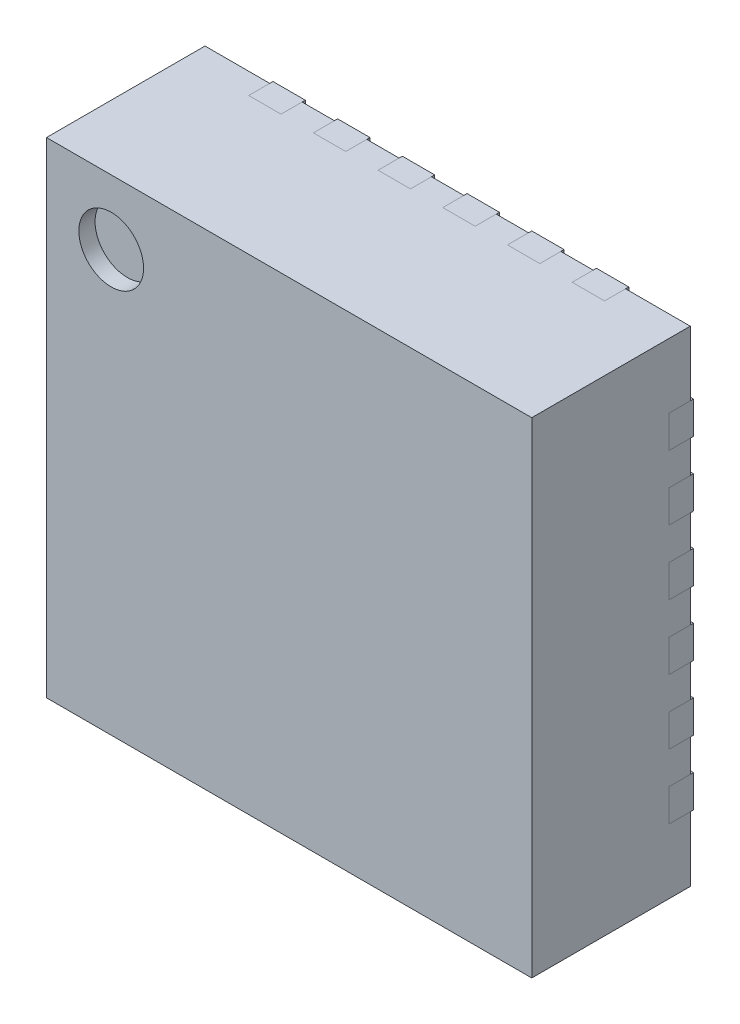
from build123d import *

# Parameters (mm, degrees)
ESQUISSE1_W                = 3
ESQUISSE1_H                = 3
BOSS_EXTRU_1_DEPTH         = 0.98
ENL_V_MAT_EXTRU_3_DEPTH    = 0.13
BOSS_EXTRU_3_DEPTH         = 0.13
BOSS_EXTRU_3_DEPTH_BACK    = 0.02
BOSS_EXTRU_3_2_DEPTH       = 0.13
BOSS_EXTRU_3_2_DEPTH_BACK  = 0.02
BOSS_EXTRU_3_3_DEPTH       = 0.13
BOSS_EXTRU_3_3_DEPTH_BACK  = 0.02
BOSS_EXTRU_3_4_DEPTH       = 0.13
BOSS_EXTRU_3_4_DEPTH_BACK  = 0.02
BOSS_EXTRU_3_5_DEPTH       = 0.13
BOSS_EXTRU_3_5_DEPTH_BACK  = 0.02
BOSS_EXTRU_3_6_DEPTH       = 0.13
BOSS_EXTRU_3_6_DEPTH_BACK  = 0.02
BOSS_EXTRU_3_7_DEPTH       = 0.13
BOSS_EXTRU_3_7_DEPTH_BACK  = 0.02
BOSS_EXTRU_3_8_DEPTH       = 0.13
BOSS_EXTRU_3_8_DEPTH_BACK  = 0.02
BOSS_EXTRU_3_9_DEPTH       = 0.13
BOSS_EXTRU_3_9_DEPTH_BACK  = 0.02
BOSS_EXTRU_3_10_DEPTH      = 0.13
BOSS_EXTRU_3_10_DEPTH_BACK = 0.02
BOSS_EXTRU_3_11_DEPTH      = 0.13
BOSS_EXTRU_3_11_DEPTH_BACK = 0.02
BOSS_EXTRU_3_12_DEPTH      = 0.13
BOSS_EXTRU_3_12_DEPTH_BACK = 0.02
BOSS_EXTRU_3_13_DEPTH      = 0.13
BOSS_EXTRU_3_13_DEPTH_BACK = 0.02
BOSS_EXTRU_3_14_DEPTH      = 0.13
BOSS_EXTRU_3_14_DEPTH_BACK = 0.02
BOSS_EXTRU_3_15_DEPTH      = 0.13
BOSS_EXTRU_3_15_DEPTH_BACK = 0.02
BOSS_EXTRU_3_16_DEPTH      = 0.13
BOSS_EXTRU_3_16_DEPTH_BACK = 0.02
BOSS_EXTRU_3_17_DEPTH      = 0.13
BOSS_EXTRU_3_17_DEPTH_BACK = 0.02
BOSS_EXTRU_3_18_DEPTH      = 0.13
BOSS_EXTRU_3_18_DEPTH_BACK = 0.02
BOSS_EXTRU_3_19_DEPTH      = 0.13
BOSS_EXTRU_3_19_DEPTH_BACK = 0.02
BOSS_EXTRU_3_20_DEPTH      = 0.13
BOSS_EXTRU_3_20_DEPTH_BACK = 0.02
BOSS_EXTRU_3_21_DEPTH      = 0.13
BOSS_EXTRU_3_21_DEPTH_BACK = 0.02
BOSS_EXTRU_3_22_DEPTH      = 0.13
BOSS_EXTRU_3_22_DEPTH_BACK = 0.02
BOSS_EXTRU_3_23_DEPTH      = 0.13
BOSS_EXTRU_3_23_DEPTH_BACK = 0.02
BOSS_EXTRU_3_24_DEPTH      = 0.13
BOSS_EXTRU_3_24_DEPTH_BACK = 0.02
BOSS_EXTRU_3_25_DEPTH      = 0.13
BOSS_EXTRU_3_25_DEPTH_BACK = 0.02
ESQUISSE5_R                = 0.2
ENL_V_MAT_EXTRU_4_DEPTH    = 0.1


with BuildPart() as part:
    # Esquisse1 → Boss.-Extru.1 (new body)
    with BuildSketch(Plane.XY):
        Rectangle(ESQUISSE1_W, ESQUISSE1_H)
    extrude(amount=BOSS_EXTRU_1_DEPTH)

    # Esquisse3 → Enlèv. mat.-Extru.3 (cut)
    with BuildSketch(Plane.XY):
        with BuildLine():
            Line((-1.275, -0.5), (-1.5, -0.5))
            Line((-1.5, -0.5), (-1.5, -0.7))
            Line((-1.5, -0.7), (-1.275, -0.7))
            ThreePointArc((-1.275, -0.7), (-1.221966991, -0.678033009), (-1.2, -0.625))
            Line((-1.2, -0.625), (-1.2, -0.575))
            ThreePointArc((-1.2, -0.575), (-1.221966991, -0.521966991), (-1.275, -0.5))
        make_face()
        with BuildLine():
            Line((0.85, 0.62), (0.85, -0.62))
            ThreePointArc((0.85, -0.62), (0.806066017, -0.726066017), (0.7, -0.77))
            Line((0.7, -0.77), (-0.7, -0.77))
            ThreePointArc((-0.7, -0.77), (-0.806066017, -0.726066017), (-0.85, -0.62))
            Line((-0.85, -0.62), (-0.85, 0.52))
            Line((-0.85, 0.52), (-0.6, 0.77))
            Line((-0.6, 0.77), (0.7, 0.77))
            ThreePointArc((0.7, 0.77), (0.806066017, 0.726066017), (0.85, 0.62))
        make_face()
        with BuildLine():
            Line((-1.5, 1.1), (-1.28, 1.1))
            ThreePointArc((-1.28, 1.1), (-1.220323996, 1.053117336), (-1.2, 0.98))
            ThreePointArc((-1.2, 0.98), (-1.223431458, 0.923431458), (-1.28, 0.9))
            Line((-1.28, 0.9), (-1.5, 0.9))
            Line((-1.5, 0.9), (-1.5, 1.1))
        make_face()
        with BuildLine():
            Line((-1.5, -0.1), (-1.5, -0.3))
            Line((-1.5, -0.3), (-1.275, -0.3))
            ThreePointArc((-1.275, -0.3), (-1.221966991, -0.278033009), (-1.2, -0.225))
            Line((-1.2, -0.225), (-1.2, -0.175))
            ThreePointArc((-1.2, -0.175), (-1.221966991, -0.121966991), (-1.275, -0.1))
            Line((-1.275, -0.1), (-1.5, -0.1))
        make_face()
        with BuildLine():
            Line((-1.5, 0.3), (-1.5, 0.1))
            Line((-1.5, 0.1), (-1.275, 0.1))
            ThreePointArc((-1.275, 0.1), (-1.221966991, 0.121966991), (-1.2, 0.175))
            Line((-1.2, 0.175), (-1.2, 0.225))
            ThreePointArc((-1.2, 0.225), (-1.221966991, 0.278033009), (-1.275, 0.3))
            Line((-1.275, 0.3), (-1.5, 0.3))
        make_face()
        with BuildLine():
            Line((-1.5, 0.7), (-1.5, 0.5))
            Line((-1.5, 0.5), (-1.275, 0.5))
            ThreePointArc((-1.275, 0.5), (-1.221966991, 0.521966991), (-1.2, 0.575))
            Line((-1.2, 0.575), (-1.2, 0.625))
            ThreePointArc((-1.2, 0.625), (-1.221966991, 0.678033009), (-1.275, 0.7))
            Line((-1.275, 0.7), (-1.5, 0.7))
        make_face()
        with BuildLine():
            Line((-1.5, -0.9), (-1.5, -1.1))
            Line((-1.5, -1.1), (-1.28, -1.1))
            ThreePointArc((-1.28, -1.1), (-1.220323996, -1.053117336), (-1.2, -0.98))
            ThreePointArc((-1.2, -0.98), (-1.223431458, -0.923431458), (-1.28, -0.9))
            Line((-1.28, -0.9), (-1.5, -0.9))
        make_face()
        with BuildLine():
            Line((1.1, 1.5), (1.1, 1.28))
            ThreePointArc((1.1, 1.28), (1.053117336, 1.220323996), (0.98, 1.2))
            ThreePointArc((0.98, 1.2), (0.923431458, 1.223431458), (0.9, 1.28))
            Line((0.9, 1.28), (0.9, 1.5))
            Line((0.9, 1.5), (1.1, 1.5))
        make_face()
        with BuildLine():
            Line((0.7, 1.5), (0.5, 1.5))
            Line((0.5, 1.5), (0.5, 1.275))
            ThreePointArc((0.5, 1.275), (0.521966991, 1.221966991), (0.575, 1.2))
            Line((0.575, 1.2), (0.625, 1.2))
            ThreePointArc((0.625, 1.2), (0.678033009, 1.221966991), (0.7, 1.275))
            Line((0.7, 1.275), (0.7, 1.5))
        make_face()
        with BuildLine():
            Line((0.3, 1.5), (0.1, 1.5))
            Line((0.1, 1.5), (0.1, 1.275))
            ThreePointArc((0.1, 1.275), (0.121966991, 1.221966991), (0.175, 1.2))
            Line((0.175, 1.2), (0.225, 1.2))
            ThreePointArc((0.225, 1.2), (0.278033009, 1.221966991), (0.3, 1.275))
            Line((0.3, 1.275), (0.3, 1.5))
        make_face()
        with BuildLine():
            Line((-0.1, 1.5), (-0.3, 1.5))
            Line((-0.3, 1.5), (-0.3, 1.275))
            ThreePointArc((-0.3, 1.275), (-0.278033009, 1.221966991), (-0.225, 1.2))
            Line((-0.225, 1.2), (-0.175, 1.2))
            ThreePointArc((-0.175, 1.2), (-0.121966991, 1.221966991), (-0.1, 1.275))
            Line((-0.1, 1.275), (-0.1, 1.5))
        make_face()
        with BuildLine():
            Line((1.5, -1.1), (1.28, -1.1))
            ThreePointArc((1.28, -1.1), (1.220323996, -1.053117336), (1.2, -0.98))
            ThreePointArc((1.2, -0.98), (1.223431458, -0.923431458), (1.28, -0.9))
            Line((1.28, -0.9), (1.5, -0.9))
            Line((1.5, -0.9), (1.5, -1.1))
        make_face()
        with BuildLine():
            Line((1.5, -0.7), (1.5, -0.5))
            Line((1.5, -0.5), (1.275, -0.5))
            ThreePointArc((1.275, -0.5), (1.221966991, -0.521966991), (1.2, -0.575))
            Line((1.2, -0.575), (1.2, -0.625))
            ThreePointArc((1.2, -0.625), (1.221966991, -0.678033009), (1.275, -0.7))
            Line((1.275, -0.7), (1.5, -0.7))
        make_face()
        with BuildLine():
            Line((1.5, -0.3), (1.5, -0.1))
            Line((1.5, -0.1), (1.275, -0.1))
            ThreePointArc((1.275, -0.1), (1.221966991, -0.121966991), (1.2, -0.175))
            Line((1.2, -0.175), (1.2, -0.225))
            ThreePointArc((1.2, -0.225), (1.221966991, -0.278033009), (1.275, -0.3))
            Line((1.275, -0.3), (1.5, -0.3))
        make_face()
        with BuildLine():
            Line((1.5, 0.1), (1.5, 0.3))
            Line((1.5, 0.3), (1.275, 0.3))
            ThreePointArc((1.275, 0.3), (1.221966991, 0.278033009), (1.2, 0.225))
            Line((1.2, 0.225), (1.2, 0.175))
            ThreePointArc((1.2, 0.175), (1.221966991, 0.121966991), (1.275, 0.1))
            Line((1.275, 0.1), (1.5, 0.1))
        make_face()
        with BuildLine():
            Line((-1.1, -1.5), (-1.1, -1.28))
            ThreePointArc((-1.1, -1.28), (-1.053117336, -1.220323996), (-0.98, -1.2))
            ThreePointArc((-0.98, -1.2), (-0.923431458, -1.223431458), (-0.9, -1.28))
            Line((-0.9, -1.28), (-0.9, -1.5))
            Line((-0.9, -1.5), (-1.1, -1.5))
        make_face()
        with BuildLine():
            Line((-0.7, -1.5), (-0.5, -1.5))
            Line((-0.5, -1.5), (-0.5, -1.275))
            ThreePointArc((-0.5, -1.275), (-0.521966991, -1.221966991), (-0.575, -1.2))
            Line((-0.575, -1.2), (-0.625, -1.2))
            ThreePointArc((-0.625, -1.2), (-0.678033009, -1.221966991), (-0.7, -1.275))
            Line((-0.7, -1.275), (-0.7, -1.5))
        make_face()
        with BuildLine():
            Line((-0.3, -1.5), (-0.1, -1.5))
            Line((-0.1, -1.5), (-0.1, -1.275))
            ThreePointArc((-0.1, -1.275), (-0.121966991, -1.221966991), (-0.175, -1.2))
            Line((-0.175, -1.2), (-0.225, -1.2))
            ThreePointArc((-0.225, -1.2), (-0.278033009, -1.221966991), (-0.3, -1.275))
            Line((-0.3, -1.275), (-0.3, -1.5))
        make_face()
        with BuildLine():
            Line((0.1, -1.5), (0.3, -1.5))
            Line((0.3, -1.5), (0.3, -1.275))
            ThreePointArc((0.3, -1.275), (0.278033009, -1.221966991), (0.225, -1.2))
            Line((0.225, -1.2), (0.175, -1.2))
            ThreePointArc((0.175, -1.2), (0.121966991, -1.221966991), (0.1, -1.275))
            Line((0.1, -1.275), (0.1, -1.5))
        make_face()
        with BuildLine():
            Line((-0.5, 1.5), (-0.7, 1.5))
            Line((-0.7, 1.5), (-0.7, 1.275))
            ThreePointArc((-0.7, 1.275), (-0.678033009, 1.221966991), (-0.625, 1.2))
            Line((-0.625, 1.2), (-0.575, 1.2))
            ThreePointArc((-0.575, 1.2), (-0.521966991, 1.221966991), (-0.5, 1.275))
            Line((-0.5, 1.275), (-0.5, 1.5))
        make_face()
        with BuildLine():
            Line((-0.9, 1.5), (-1.1, 1.5))
            Line((-1.1, 1.5), (-1.1, 1.28))
            ThreePointArc((-1.1, 1.28), (-1.053117336, 1.220323996), (-0.98, 1.2))
            ThreePointArc((-0.98, 1.2), (-0.923431458, 1.223431458), (-0.9, 1.28))
            Line((-0.9, 1.28), (-0.9, 1.5))
        make_face()
        with BuildLine():
            Line((1.5, 0.5), (1.5, 0.7))
            Line((1.5, 0.7), (1.275, 0.7))
            ThreePointArc((1.275, 0.7), (1.221966991, 0.678033009), (1.2, 0.625))
            Line((1.2, 0.625), (1.2, 0.575))
            ThreePointArc((1.2, 0.575), (1.221966991, 0.521966991), (1.275, 0.5))
            Line((1.275, 0.5), (1.5, 0.5))
        make_face()
        with BuildLine():
            Line((1.5, 0.9), (1.5, 1.1))
            Line((1.5, 1.1), (1.28, 1.1))
            ThreePointArc((1.28, 1.1), (1.220323996, 1.053117336), (1.2, 0.98))
            ThreePointArc((1.2, 0.98), (1.223431458, 0.923431458), (1.28, 0.9))
            Line((1.28, 0.9), (1.5, 0.9))
        make_face()
        with BuildLine():
            Line((0.5, -1.5), (0.7, -1.5))
            Line((0.7, -1.5), (0.7, -1.275))
            ThreePointArc((0.7, -1.275), (0.678033009, -1.221966991), (0.625, -1.2))
            Line((0.625, -1.2), (0.575, -1.2))
            ThreePointArc((0.575, -1.2), (0.521966991, -1.221966991), (0.5, -1.275))
            Line((0.5, -1.275), (0.5, -1.5))
        make_face()
        with BuildLine():
            Line((0.9, -1.5), (1.1, -1.5))
            Line((1.1, -1.5), (1.1, -1.28))
            ThreePointArc((1.1, -1.28), (1.053117336, -1.220323996), (0.98, -1.2))
            ThreePointArc((0.98, -1.2), (0.923431458, -1.223431458), (0.9, -1.28))
            Line((0.9, -1.28), (0.9, -1.5))
        make_face()
    extrude(amount=ENL_V_MAT_EXTRU_3_DEPTH, mode=Mode.SUBTRACT)

    # Esquisse5 → Enlèv. mat.-Extru.4 (cut)
    with BuildSketch(Plane.XY.offset(0.98)):
        with Locations((-1.1, 1.1)):
            Circle(ESQUISSE5_R)
    extrude(amount=-ENL_V_MAT_EXTRU_4_DEPTH, mode=Mode.SUBTRACT)


with BuildPart() as body_2:
    # Esquisse4 → Boss.-Extru.3 (new body, two sides)
    with BuildSketch(Plane.XY) as boss_extru_3_sk:
        with BuildLine():
            Line((-1.275, -0.5), (-1.5, -0.5))
            Line((-1.5, -0.5), (-1.5, -0.7))
            Line((-1.5, -0.7), (-1.275, -0.7))
            ThreePointArc((-1.275, -0.7), (-1.221966991, -0.678033009), (-1.2, -0.625))
            Line((-1.2, -0.625), (-1.2, -0.575))
            ThreePointArc((-1.2, -0.575), (-1.221966991, -0.521966991), (-1.275, -0.5))
        make_face()
    extrude(amount=BOSS_EXTRU_3_DEPTH)
    extrude(boss_extru_3_sk.sketch, amount=-BOSS_EXTRU_3_DEPTH_BACK)


with BuildPart() as body_3:
    # Esquisse4 → Boss.-Extru.3 2 (new body, two sides)
    with BuildSketch(Plane.XY) as boss_extru_3_2_sk:
        with BuildLine():
            Line((0.85, 0.62), (0.85, -0.62))
            ThreePointArc((0.85, -0.62), (0.806066017, -0.726066017), (0.7, -0.77))
            Line((0.7, -0.77), (-0.7, -0.77))
            ThreePointArc((-0.7, -0.77), (-0.806066017, -0.726066017), (-0.85, -0.62))
            Line((-0.85, -0.62), (-0.85, 0.52))
            Line((-0.85, 0.52), (-0.6, 0.77))
            Line((-0.6, 0.77), (0.7, 0.77))
            ThreePointArc((0.7, 0.77), (0.806066017, 0.726066017), (0.85, 0.62))
        make_face()
    extrude(amount=BOSS_EXTRU_3_2_DEPTH)
    extrude(boss_extru_3_2_sk.sketch, amount=-BOSS_EXTRU_3_2_DEPTH_BACK)


with BuildPart() as body_4:
    # Esquisse4 → Boss.-Extru.3 3 (new body, two sides)
    with BuildSketch(Plane.XY) as boss_extru_3_3_sk:
        with BuildLine():
            Line((-1.5, 1.1), (-1.28, 1.1))
            ThreePointArc((-1.28, 1.1), (-1.220323996, 1.053117336), (-1.2, 0.98))
            ThreePointArc((-1.2, 0.98), (-1.223431458, 0.923431458), (-1.28, 0.9))
            Line((-1.28, 0.9), (-1.5, 0.9))
            Line((-1.5, 0.9), (-1.5, 1.1))
        make_face()
    extrude(amount=BOSS_EXTRU_3_3_DEPTH)
    extrude(boss_extru_3_3_sk.sketch, amount=-BOSS_EXTRU_3_3_DEPTH_BACK)


with BuildPart() as body_5:
    # Esquisse4 → Boss.-Extru.3 4 (new body, two sides)
    with BuildSketch(Plane.XY) as boss_extru_3_4_sk:
        with BuildLine():
            Line((-1.5, -0.1), (-1.5, -0.3))
            Line((-1.5, -0.3), (-1.275, -0.3))
            ThreePointArc((-1.275, -0.3), (-1.221966991, -0.278033009), (-1.2, -0.225))
            Line((-1.2, -0.225), (-1.2, -0.175))
            ThreePointArc((-1.2, -0.175), (-1.221966991, -0.121966991), (-1.275, -0.1))
            Line((-1.275, -0.1), (-1.5, -0.1))
        make_face()
    extrude(amount=BOSS_EXTRU_3_4_DEPTH)
    extrude(boss_extru_3_4_sk.sketch, amount=-BOSS_EXTRU_3_4_DEPTH_BACK)


with BuildPart() as body_6:
    # Esquisse4 → Boss.-Extru.3 5 (new body, two sides)
    with BuildSketch(Plane.XY) as boss_extru_3_5_sk:
        with BuildLine():
            Line((-1.5, 0.3), (-1.5, 0.1))
            Line((-1.5, 0.1), (-1.275, 0.1))
            ThreePointArc((-1.275, 0.1), (-1.221966991, 0.121966991), (-1.2, 0.175))
            Line((-1.2, 0.175), (-1.2, 0.225))
            ThreePointArc((-1.2, 0.225), (-1.221966991, 0.278033009), (-1.275, 0.3))
            Line((-1.275, 0.3), (-1.5, 0.3))
        make_face()
    extrude(amount=BOSS_EXTRU_3_5_DEPTH)
    extrude(boss_extru_3_5_sk.sketch, amount=-BOSS_EXTRU_3_5_DEPTH_BACK)


with BuildPart() as body_7:
    # Esquisse4 → Boss.-Extru.3 6 (new body, two sides)
    with BuildSketch(Plane.XY) as boss_extru_3_6_sk:
        with BuildLine():
            Line((-1.5, 0.7), (-1.5, 0.5))
            Line((-1.5, 0.5), (-1.275, 0.5))
            ThreePointArc((-1.275, 0.5), (-1.221966991, 0.521966991), (-1.2, 0.575))
            Line((-1.2, 0.575), (-1.2, 0.625))
            ThreePointArc((-1.2, 0.625), (-1.221966991, 0.678033009), (-1.275, 0.7))
            Line((-1.275, 0.7), (-1.5, 0.7))
        make_face()
    extrude(amount=BOSS_EXTRU_3_6_DEPTH)
    extrude(boss_extru_3_6_sk.sketch, amount=-BOSS_EXTRU_3_6_DEPTH_BACK)


with BuildPart() as body_8:
    # Esquisse4 → Boss.-Extru.3 7 (new body, two sides)
    with BuildSketch(Plane.XY) as boss_extru_3_7_sk:
        with BuildLine():
            Line((-1.5, -0.9), (-1.5, -1.1))
            Line((-1.5, -1.1), (-1.28, -1.1))
            ThreePointArc((-1.28, -1.1), (-1.220323996, -1.053117336), (-1.2, -0.98))
            ThreePointArc((-1.2, -0.98), (-1.223431458, -0.923431458), (-1.28, -0.9))
            Line((-1.28, -0.9), (-1.5, -0.9))
        make_face()
    extrude(amount=BOSS_EXTRU_3_7_DEPTH)
    extrude(boss_extru_3_7_sk.sketch, amount=-BOSS_EXTRU_3_7_DEPTH_BACK)


with BuildPart() as body_9:
    # Esquisse4 → Boss.-Extru.3 8 (new body, two sides)
    with BuildSketch(Plane.XY) as boss_extru_3_8_sk:
        with BuildLine():
            Line((1.1, 1.5), (1.1, 1.28))
            ThreePointArc((1.1, 1.28), (1.053117336, 1.220323996), (0.98, 1.2))
            ThreePointArc((0.98, 1.2), (0.923431458, 1.223431458), (0.9, 1.28))
            Line((0.9, 1.28), (0.9, 1.5))
            Line((0.9, 1.5), (1.1, 1.5))
        make_face()
    extrude(amount=BOSS_EXTRU_3_8_DEPTH)
    extrude(boss_extru_3_8_sk.sketch, amount=-BOSS_EXTRU_3_8_DEPTH_BACK)


with BuildPart() as body_10:
    # Esquisse4 → Boss.-Extru.3 9 (new body, two sides)
    with BuildSketch(Plane.XY) as boss_extru_3_9_sk:
        with BuildLine():
            Line((0.7, 1.5), (0.5, 1.5))
            Line((0.5, 1.5), (0.5, 1.275))
            ThreePointArc((0.5, 1.275), (0.521966991, 1.221966991), (0.575, 1.2))
            Line((0.575, 1.2), (0.625, 1.2))
            ThreePointArc((0.625, 1.2), (0.678033009, 1.221966991), (0.7, 1.275))
            Line((0.7, 1.275), (0.7, 1.5))
        make_face()
    extrude(amount=BOSS_EXTRU_3_9_DEPTH)
    extrude(boss_extru_3_9_sk.sketch, amount=-BOSS_EXTRU_3_9_DEPTH_BACK)


with BuildPart() as body_11:
    # Esquisse4 → Boss.-Extru.3 10 (new body, two sides)
    with BuildSketch(Plane.XY) as boss_extru_3_10_sk:
        with BuildLine():
            Line((0.3, 1.5), (0.1, 1.5))
            Line((0.1, 1.5), (0.1, 1.275))
            ThreePointArc((0.1, 1.275), (0.121966991, 1.221966991), (0.175, 1.2))
            Line((0.175, 1.2), (0.225, 1.2))
            ThreePointArc((0.225, 1.2), (0.278033009, 1.221966991), (0.3, 1.275))
            Line((0.3, 1.275), (0.3, 1.5))
        make_face()
    extrude(amount=BOSS_EXTRU_3_10_DEPTH)
    extrude(boss_extru_3_10_sk.sketch, amount=-BOSS_EXTRU_3_10_DEPTH_BACK)


with BuildPart() as body_12:
    # Esquisse4 → Boss.-Extru.3 11 (new body, two sides)
    with BuildSketch(Plane.XY) as boss_extru_3_11_sk:
        with BuildLine():
            Line((-0.1, 1.5), (-0.3, 1.5))
            Line((-0.3, 1.5), (-0.3, 1.275))
            ThreePointArc((-0.3, 1.275), (-0.278033009, 1.221966991), (-0.225, 1.2))
            Line((-0.225, 1.2), (-0.175, 1.2))
            ThreePointArc((-0.175, 1.2), (-0.121966991, 1.221966991), (-0.1, 1.275))
            Line((-0.1, 1.275), (-0.1, 1.5))
        make_face()
    extrude(amount=BOSS_EXTRU_3_11_DEPTH)
    extrude(boss_extru_3_11_sk.sketch, amount=-BOSS_EXTRU_3_11_DEPTH_BACK)


with BuildPart() as body_13:
    # Esquisse4 → Boss.-Extru.3 12 (new body, two sides)
    with BuildSketch(Plane.XY) as boss_extru_3_12_sk:
        with BuildLine():
            Line((1.5, -1.1), (1.28, -1.1))
            ThreePointArc((1.28, -1.1), (1.220323996, -1.053117336), (1.2, -0.98))
            ThreePointArc((1.2, -0.98), (1.223431458, -0.923431458), (1.28, -0.9))
            Line((1.28, -0.9), (1.5, -0.9))
            Line((1.5, -0.9), (1.5, -1.1))
        make_face()
    extrude(amount=BOSS_EXTRU_3_12_DEPTH)
    extrude(boss_extru_3_12_sk.sketch, amount=-BOSS_EXTRU_3_12_DEPTH_BACK)


with BuildPart() as body_14:
    # Esquisse4 → Boss.-Extru.3 13 (new body, two sides)
    with BuildSketch(Plane.XY) as boss_extru_3_13_sk:
        with BuildLine():
            Line((1.5, -0.7), (1.5, -0.5))
            Line((1.5, -0.5), (1.275, -0.5))
            ThreePointArc((1.275, -0.5), (1.221966991, -0.521966991), (1.2, -0.575))
            Line((1.2, -0.575), (1.2, -0.625))
            ThreePointArc((1.2, -0.625), (1.221966991, -0.678033009), (1.275, -0.7))
            Line((1.275, -0.7), (1.5, -0.7))
        make_face()
    extrude(amount=BOSS_EXTRU_3_13_DEPTH)
    extrude(boss_extru_3_13_sk.sketch, amount=-BOSS_EXTRU_3_13_DEPTH_BACK)


with BuildPart() as body_15:
    # Esquisse4 → Boss.-Extru.3 14 (new body, two sides)
    with BuildSketch(Plane.XY) as boss_extru_3_14_sk:
        with BuildLine():
            Line((1.5, -0.3), (1.5, -0.1))
            Line((1.5, -0.1), (1.275, -0.1))
            ThreePointArc((1.275, -0.1), (1.221966991, -0.121966991), (1.2, -0.175))
            Line((1.2, -0.175), (1.2, -0.225))
            ThreePointArc((1.2, -0.225), (1.221966991, -0.278033009), (1.275, -0.3))
            Line((1.275, -0.3), (1.5, -0.3))
        make_face()
    extrude(amount=BOSS_EXTRU_3_14_DEPTH)
    extrude(boss_extru_3_14_sk.sketch, amount=-BOSS_EXTRU_3_14_DEPTH_BACK)


with BuildPart() as body_16:
    # Esquisse4 → Boss.-Extru.3 15 (new body, two sides)
    with BuildSketch(Plane.XY) as boss_extru_3_15_sk:
        with BuildLine():
            Line((1.5, 0.1), (1.5, 0.3))
            Line((1.5, 0.3), (1.275, 0.3))
            ThreePointArc((1.275, 0.3), (1.221966991, 0.278033009), (1.2, 0.225))
            Line((1.2, 0.225), (1.2, 0.175))
            ThreePointArc((1.2, 0.175), (1.221966991, 0.121966991), (1.275, 0.1))
            Line((1.275, 0.1), (1.5, 0.1))
        make_face()
    extrude(amount=BOSS_EXTRU_3_15_DEPTH)
    extrude(boss_extru_3_15_sk.sketch, amount=-BOSS_EXTRU_3_15_DEPTH_BACK)


with BuildPart() as body_17:
    # Esquisse4 → Boss.-Extru.3 16 (new body, two sides)
    with BuildSketch(Plane.XY) as boss_extru_3_16_sk:
        with BuildLine():
            Line((-1.1, -1.5), (-1.1, -1.28))
            ThreePointArc((-1.1, -1.28), (-1.053117336, -1.220323996), (-0.98, -1.2))
            ThreePointArc((-0.98, -1.2), (-0.923431458, -1.223431458), (-0.9, -1.28))
            Line((-0.9, -1.28), (-0.9, -1.5))
            Line((-0.9, -1.5), (-1.1, -1.5))
        make_face()
    extrude(amount=BOSS_EXTRU_3_16_DEPTH)
    extrude(boss_extru_3_16_sk.sketch, amount=-BOSS_EXTRU_3_16_DEPTH_BACK)


with BuildPart() as body_18:
    # Esquisse4 → Boss.-Extru.3 17 (new body, two sides)
    with BuildSketch(Plane.XY) as boss_extru_3_17_sk:
        with BuildLine():
            Line((-0.7, -1.5), (-0.5, -1.5))
            Line((-0.5, -1.5), (-0.5, -1.275))
            ThreePointArc((-0.5, -1.275), (-0.521966991, -1.221966991), (-0.575, -1.2))
            Line((-0.575, -1.2), (-0.625, -1.2))
            ThreePointArc((-0.625, -1.2), (-0.678033009, -1.221966991), (-0.7, -1.275))
            Line((-0.7, -1.275), (-0.7, -1.5))
        make_face()
    extrude(amount=BOSS_EXTRU_3_17_DEPTH)
    extrude(boss_extru_3_17_sk.sketch, amount=-BOSS_EXTRU_3_17_DEPTH_BACK)


with BuildPart() as body_19:
    # Esquisse4 → Boss.-Extru.3 18 (new body, two sides)
    with BuildSketch(Plane.XY) as boss_extru_3_18_sk:
        with BuildLine():
            Line((-0.3, -1.5), (-0.1, -1.5))
            Line((-0.1, -1.5), (-0.1, -1.275))
            ThreePointArc((-0.1, -1.275), (-0.121966991, -1.221966991), (-0.175, -1.2))
            Line((-0.175, -1.2), (-0.225, -1.2))
            ThreePointArc((-0.225, -1.2), (-0.278033009, -1.221966991), (-0.3, -1.275))
            Line((-0.3, -1.275), (-0.3, -1.5))
        make_face()
    extrude(amount=BOSS_EXTRU_3_18_DEPTH)
    extrude(boss_extru_3_18_sk.sketch, amount=-BOSS_EXTRU_3_18_DEPTH_BACK)


with BuildPart() as body_20:
    # Esquisse4 → Boss.-Extru.3 19 (new body, two sides)
    with BuildSketch(Plane.XY) as boss_extru_3_19_sk:
        with BuildLine():
            Line((0.1, -1.5), (0.3, -1.5))
            Line((0.3, -1.5), (0.3, -1.275))
            ThreePointArc((0.3, -1.275), (0.278033009, -1.221966991), (0.225, -1.2))
            Line((0.225, -1.2), (0.175, -1.2))
            ThreePointArc((0.175, -1.2), (0.121966991, -1.221966991), (0.1, -1.275))
            Line((0.1, -1.275), (0.1, -1.5))
        make_face()
    extrude(amount=BOSS_EXTRU_3_19_DEPTH)
    extrude(boss_extru_3_19_sk.sketch, amount=-BOSS_EXTRU_3_19_DEPTH_BACK)


with BuildPart() as body_21:
    # Esquisse4 → Boss.-Extru.3 20 (new body, two sides)
    with BuildSketch(Plane.XY) as boss_extru_3_20_sk:
        with BuildLine():
            Line((-0.5, 1.5), (-0.7, 1.5))
            Line((-0.7, 1.5), (-0.7, 1.275))
            ThreePointArc((-0.7, 1.275), (-0.678033009, 1.221966991), (-0.625, 1.2))
            Line((-0.625, 1.2), (-0.575, 1.2))
            ThreePointArc((-0.575, 1.2), (-0.521966991, 1.221966991), (-0.5, 1.275))
            Line((-0.5, 1.275), (-0.5, 1.5))
        make_face()
    extrude(amount=BOSS_EXTRU_3_20_DEPTH)
    extrude(boss_extru_3_20_sk.sketch, amount=-BOSS_EXTRU_3_20_DEPTH_BACK)


with BuildPart() as body_22:
    # Esquisse4 → Boss.-Extru.3 21 (new body, two sides)
    with BuildSketch(Plane.XY) as boss_extru_3_21_sk:
        with BuildLine():
            Line((-0.9, 1.5), (-1.1, 1.5))
            Line((-1.1, 1.5), (-1.1, 1.28))
            ThreePointArc((-1.1, 1.28), (-1.053117336, 1.220323996), (-0.98, 1.2))
            ThreePointArc((-0.98, 1.2), (-0.923431458, 1.223431458), (-0.9, 1.28))
            Line((-0.9, 1.28), (-0.9, 1.5))
        make_face()
    extrude(amount=BOSS_EXTRU_3_21_DEPTH)
    extrude(boss_extru_3_21_sk.sketch, amount=-BOSS_EXTRU_3_21_DEPTH_BACK)


with BuildPart() as body_23:
    # Esquisse4 → Boss.-Extru.3 22 (new body, two sides)
    with BuildSketch(Plane.XY) as boss_extru_3_22_sk:
        with BuildLine():
            Line((1.5, 0.5), (1.5, 0.7))
            Line((1.5, 0.7), (1.275, 0.7))
            ThreePointArc((1.275, 0.7), (1.221966991, 0.678033009), (1.2, 0.625))
            Line((1.2, 0.625), (1.2, 0.575))
            ThreePointArc((1.2, 0.575), (1.221966991, 0.521966991), (1.275, 0.5))
            Line((1.275, 0.5), (1.5, 0.5))
        make_face()
    extrude(amount=BOSS_EXTRU_3_22_DEPTH)
    extrude(boss_extru_3_22_sk.sketch, amount=-BOSS_EXTRU_3_22_DEPTH_BACK)


with BuildPart() as body_24:
    # Esquisse4 → Boss.-Extru.3 23 (new body, two sides)
    with BuildSketch(Plane.XY) as boss_extru_3_23_sk:
        with BuildLine():
            Line((1.5, 0.9), (1.5, 1.1))
            Line((1.5, 1.1), (1.28, 1.1))
            ThreePointArc((1.28, 1.1), (1.220323996, 1.053117336), (1.2, 0.98))
            ThreePointArc((1.2, 0.98), (1.223431458, 0.923431458), (1.28, 0.9))
            Line((1.28, 0.9), (1.5, 0.9))
        make_face()
    extrude(amount=BOSS_EXTRU_3_23_DEPTH)
    extrude(boss_extru_3_23_sk.sketch, amount=-BOSS_EXTRU_3_23_DEPTH_BACK)


with BuildPart() as body_25:
    # Esquisse4 → Boss.-Extru.3 24 (new body, two sides)
    with BuildSketch(Plane.XY) as boss_extru_3_24_sk:
        with BuildLine():
            Line((0.5, -1.5), (0.7, -1.5))
            Line((0.7, -1.5), (0.7, -1.275))
            ThreePointArc((0.7, -1.275), (0.678033009, -1.221966991), (0.625, -1.2))
            Line((0.625, -1.2), (0.575, -1.2))
            ThreePointArc((0.575, -1.2), (0.521966991, -1.221966991), (0.5, -1.275))
            Line((0.5, -1.275), (0.5, -1.5))
        make_face()
    extrude(amount=BOSS_EXTRU_3_24_DEPTH)
    extrude(boss_extru_3_24_sk.sketch, amount=-BOSS_EXTRU_3_24_DEPTH_BACK)


with BuildPart() as body_26:
    # Esquisse4 → Boss.-Extru.3 25 (new body, two sides)
    with BuildSketch(Plane.XY) as boss_extru_3_25_sk:
        with BuildLine():
            Line((0.9, -1.5), (1.1, -1.5))
            Line((1.1, -1.5), (1.1, -1.28))
            ThreePointArc((1.1, -1.28), (1.053117336, -1.220323996), (0.98, -1.2))
            ThreePointArc((0.98, -1.2), (0.923431458, -1.223431458), (0.9, -1.28))
            Line((0.9, -1.28), (0.9, -1.5))
        make_face()
    extrude(amount=BOSS_EXTRU_3_25_DEPTH)
    extrude(boss_extru_3_25_sk.sketch, amount=-BOSS_EXTRU_3_25_DEPTH_BACK)


solid = Compound([part.part, body_2.part, body_3.part, body_4.part, body_5.part, body_6.part, body_7.part, body_8.part, body_9.part, body_10.part, body_11.part, body_12.part, body_13.part, body_14.part, body_15.part, body_16.part, body_17.part, body_18.part, body_19.part, body_20.part, body_21.part, body_22.part, body_23.part, body_24.part, body_25.part, body_26.part])
